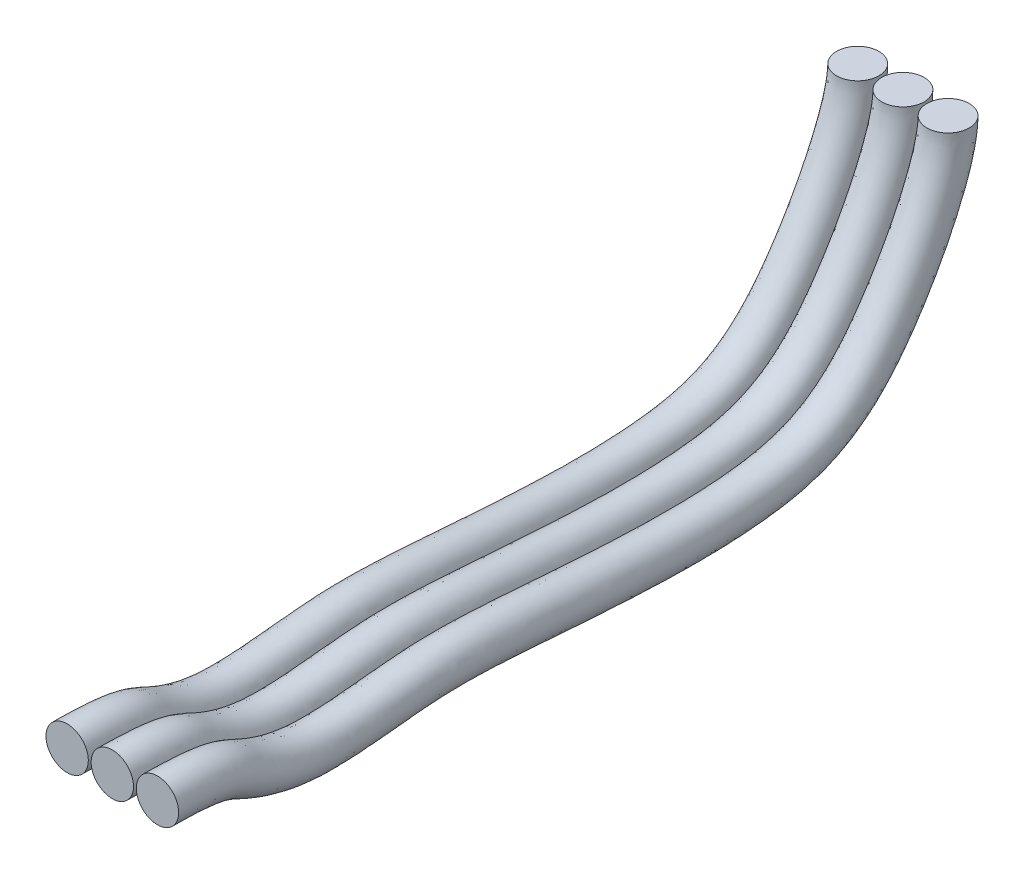
from build123d import *

# Parameters (mm, degrees)
SKETCH3_R = 0.75


with BuildPart() as part:
    # Sweep1: sweep along a path in Sketch2
    with BuildLine() as sweep1_path:  # in the path sketch's own coordinates; laid on its plane below (add() does not lay a ready-made edge on the line's plane)
        add(Edge.make_bspline(
            [(0, 0), (2.000424851, 0), (2.762905607, -0.502015218), (5.11283399, -1.316422396), (9.419538858, -0.691899159), (12.343744984, -0.831079204), (21.655109966, -1.60038256), (25.382807454, 0.465175975), (28, 5.719345887), (28, 7)],
            knots=[0, 0, 0, 0, 0.131691891, 0.270613665, 0.409751883, 0.581041375, 0.755263075, 0.891487081, 1, 1, 1, 1], degree=3))
    # Sketch3 → Sweep1 (sweep)
    with BuildSketch(Plane.XY):
        Circle(SKETCH3_R)
        with Locations((1.6, 0)):
            Circle(SKETCH3_R)
        with Locations((-1.6, 0)):
            Circle(SKETCH3_R)
    sweep(path=Plane(origin=(0, 0, 0), x_dir=(0, 0, -1), z_dir=(1, 0, 0)) * sweep1_path.line)


solid = part.part
